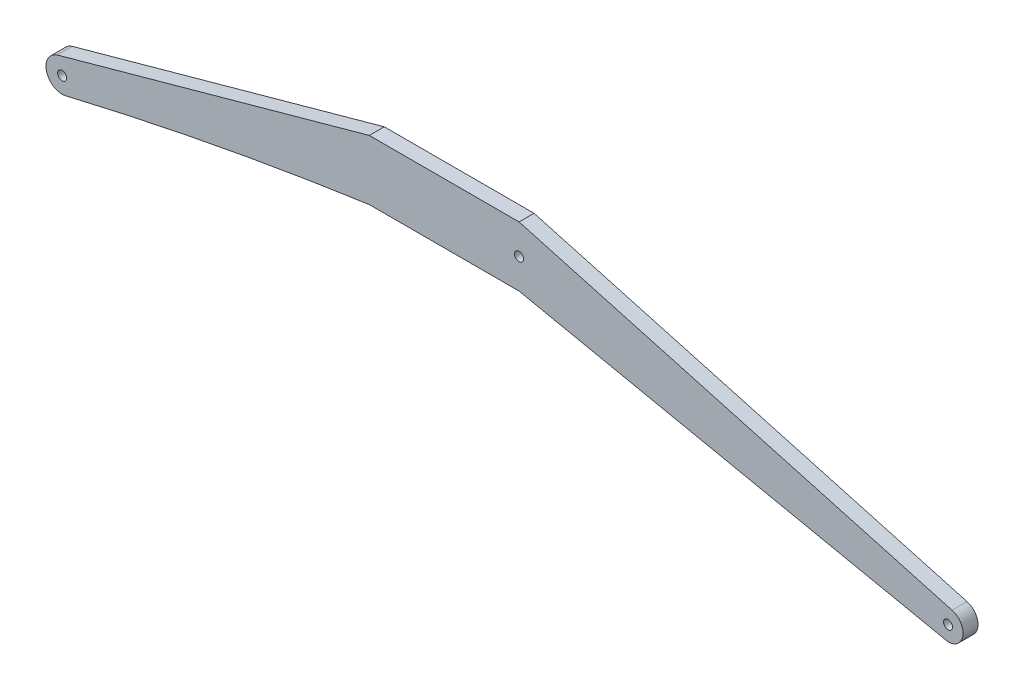
from build123d import *

# Parameters (mm, degrees)
SKETCH_1_R      = 0.3
EXTRUDE_1_DEPTH = 1


with BuildPart() as part:
    # 草图1 → 凸台-拉伸1 (new body)
    with BuildSketch(Plane.XY):
        with BuildLine():
            ThreePointArc((-24.431752563, -5.621234593), (-24.841338221, -4.775340284), (-25.758932756, -4.572072325))
            Line((-25.758932756, -4.572072325), (-25.579283033, -5.329336265))
            ThreePointArc((-25.579283033, -5.329336265), (-25.32398953, -5.385889555), (-25.210034452, -5.621234593))
            ThreePointArc((-25.210034452, -5.621234593), (-25.274689413, -5.807279515), (-25.44078587, -5.913132921))
            Line((-25.44078587, -5.913132921), (-25.261136147, -6.670396861))
            ThreePointArc((-25.261136147, -6.670396861), (-24.664140143, -6.289930824), (-24.431752563, -5.621234593))
        make_face()
        with BuildLine():
            Line((-25.579283033, -5.329336265), (-25.758932756, -4.572072325))
            Line((-25.758932756, -4.572072325), (-25.835826145, -4.593347633))
            ThreePointArc((-25.835826145, -4.593347633), (-26.54927048, -5.90877643), (-25.261136147, -6.670396861))
            Line((-25.261136147, -6.670396861), (-25.44078587, -5.913132921))
            ThreePointArc((-25.44078587, -5.913132921), (-25.80193278, -5.690483175), (-25.579283033, -5.329336265))
        make_face()
        with BuildLine():
            Line((0, 1.171629291), (-5, 1.171629291))
            Line((-5, 1.171629291), (-25.758932756, -4.572072325))
            ThreePointArc((-25.758932756, -4.572072325), (-24.841338221, -4.775340284), (-24.431752563, -5.621234593))
            ThreePointArc((-24.431752563, -5.621234593), (-24.664140143, -6.289930824), (-25.261136147, -6.670396861))
            ThreePointArc((-25.261136147, -6.670396861), (-15.17430636, -4.518727526), (-5, -2.828370709))
            Line((-5, -2.828370709), (0, -2.828370709))
            Line((0, -2.828370709), (0, 1.171629291))
        make_face()
        with BuildLine():
            Line((5, 1.171629291), (0, 1.171629291))
            Line((0, 1.171629291), (0, -2.828370709))
            Line((0, -2.828370709), (5, -2.828370709))
            Line((5, -2.828370709), (33.24792948, -8.709080669))
            Line((33.24792948, -8.709080669), (33.646997923, -8.792159528))
            ThreePointArc((33.646997923, -8.792159528), (34.637903776, -7.926716543), (33.91366459, -6.828370709))
            Line((33.91366459, -6.828370709), (5, 1.171629291))
        make_face()
        with Locations((33.646997923, -7.792159528)):
            Circle(SKETCH_1_R, mode=Mode.SUBTRACT)
        with Locations((5, -0.828370709)):
            Circle(SKETCH_1_R, mode=Mode.SUBTRACT)
    extrude(amount=EXTRUDE_1_DEPTH)


solid = part.part
